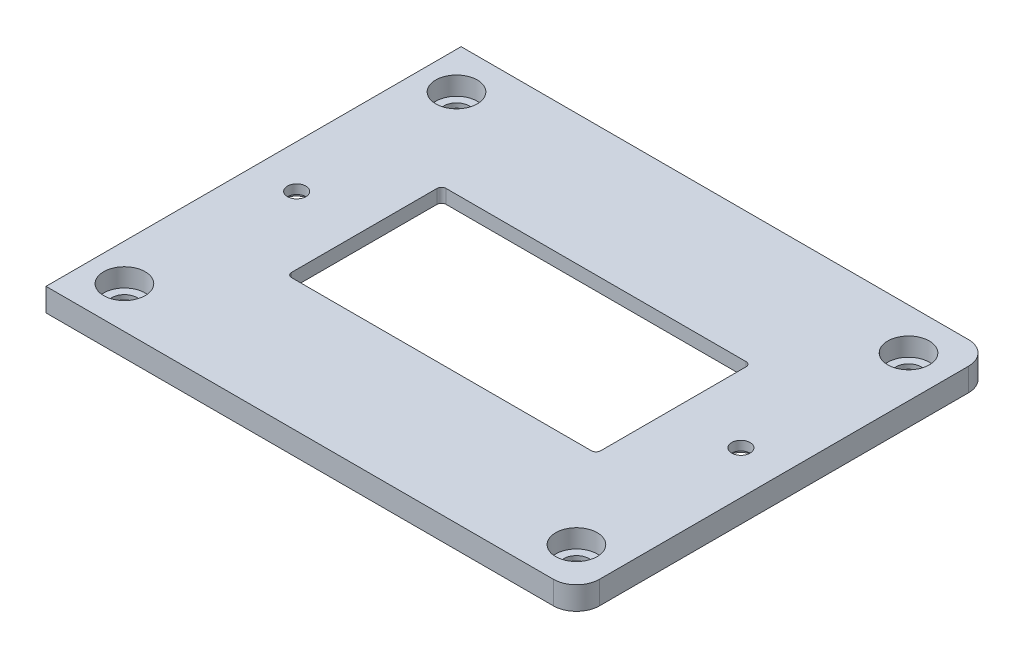
from build123d import *

# Parameters (mm, degrees)
SKETCH1_W                      = 115
SKETCH1_H                      = 90
SKETCH1_W_2                    = 67
SKETCH1_H_2                    = 33.5
BOSS_EXTRUDE1_DEPTH            = 5
FILLET1_R                      = 5
FILLET2_R                      = 1
CBORE_FOR_M5_SHCS1_D           = 5.5
CBORE_FOR_M5_SHCS1_CBORE_D     = 9
CBORE_FOR_M5_SHCS1_CBORE_DEPTH = 4
SKETCH5_W                      = 111
SKETCH5_H                      = 60
CUT_EXTRUDE1_DEPTH             = 2
CBORE_FOR_M5_SHCS2_D           = 4
CBORE_FOR_M5_SHCS2_CBORE_D     = 6
CBORE_FOR_M5_SHCS2_CBORE_DEPTH = 1


with BuildPart() as part:
    # Sketch1 → Boss-Extrude1 (new body)
    with BuildSketch(Plane(origin=(0, 0, 0), x_dir=(1, 0, 0), z_dir=(0, 1, 0))):
        Rectangle(SKETCH1_W, SKETCH1_H)
        Rectangle(SKETCH1_W_2, SKETCH1_H_2, mode=Mode.SUBTRACT)
    extrude(amount=BOSS_EXTRUDE1_DEPTH)

    # Fillet1
    fillet1_edges = [part.edges().sort_by_distance(p)[0] for p in [
        (57.5, 2.5, -45),
        (57.5, 2.5, 45),
    ]]
    fillet(fillet1_edges, radius=FILLET1_R)

    # Fillet2
    fillet2_edges = [part.edges().sort_by_distance(p)[0] for p in [
        (-33.5, 2.5, 16.75),
        (33.5, 2.5, 16.75),
        (33.5, 2.5, -16.75),
        (-33.5, 2.5, -16.75),
    ]]
    fillet(fillet2_edges, radius=FILLET2_R)

    # CBORE for M5 SHCS1 (through all)
    with Locations(Plane(origin=(0, 5, 0), x_dir=(1, 0, 0), z_dir=(0, 1, 0))):
        with Locations((-49.5, 36), (-49.5, -36), (48.5, -36), (48.5, 36)):
            CounterBoreHole(CBORE_FOR_M5_SHCS1_D / 2, CBORE_FOR_M5_SHCS1_CBORE_D / 2, CBORE_FOR_M5_SHCS1_CBORE_DEPTH)

    # Sketch5 → Cut-Extrude1 (cut)
    with BuildSketch(Plane.XZ):
        with Locations((-2, 0)):
            Rectangle(SKETCH5_W, SKETCH5_H)
    extrude(amount=-CUT_EXTRUDE1_DEPTH, mode=Mode.SUBTRACT)

    # CBORE for M5 SHCS2 (through all)
    with Locations(Plane(origin=(0, 2, 0), x_dir=(-1, 0, 0), z_dir=(0, -1, 0))):
        with Locations((48.15, 0), (-48.15, 0)):
            CounterBoreHole(CBORE_FOR_M5_SHCS2_D / 2, CBORE_FOR_M5_SHCS2_CBORE_D / 2, CBORE_FOR_M5_SHCS2_CBORE_DEPTH)


solid = part.part
